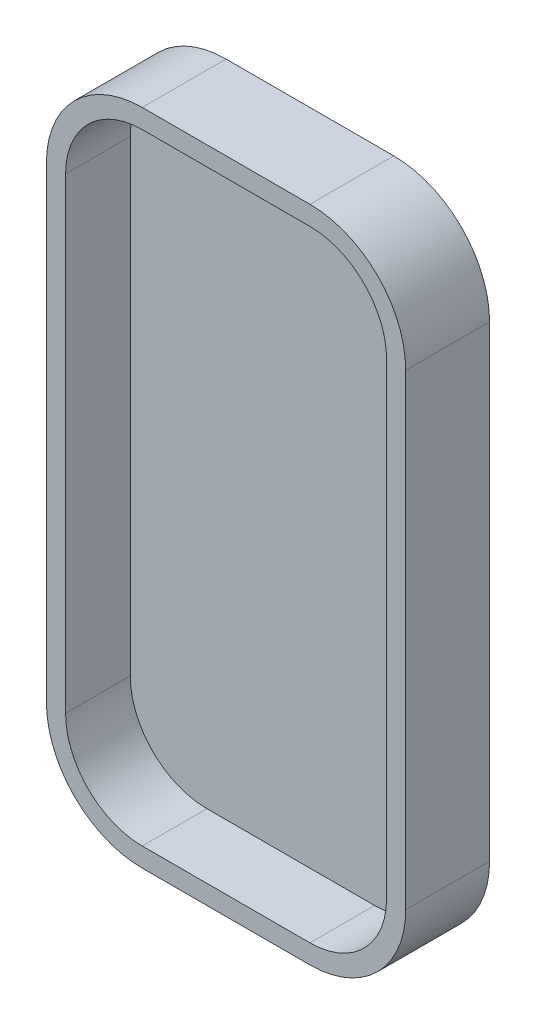
from build123d import *

# Parameters (mm, degrees)
BOSS_EXTRUDE1_DEPTH = 7
CUT_EXTRUDE1_DEPTH  = 5.4


with BuildPart() as part:
    # Sketch1 → Boss-Extrude1 (new body)
    with BuildSketch(Plane(origin=(0, 0, 0), x_dir=(0, 1, 0), z_dir=(0, 0, 1))):
        with BuildLine():
            Line((-19.5, 15), (19.5, 15))
            ThreePointArc((19.5, 15), (25.156854249, 12.656854249), (27.5, 7))
            Line((27.5, 7), (27.5, -7))
            ThreePointArc((27.5, -7), (25.156854249, -12.656854249), (19.5, -15))
            Line((19.5, -15), (-19.5, -15))
            ThreePointArc((-19.5, -15), (-25.156854249, -12.656854249), (-27.5, -7))
            Line((-27.5, -7), (-27.5, 7))
            ThreePointArc((-27.5, 7), (-25.156854249, 12.656854249), (-19.5, 15))
        make_face()
    extrude(amount=BOSS_EXTRUDE1_DEPTH)

    # Sketch2 → Cut-Extrude1 (cut)
    with BuildSketch(Plane.XY.offset(7)):
        with BuildLine():
            Line((7, -25.9), (-7, -25.9))
            ThreePointArc((-7, -25.9), (-11.5254834, -24.0254834), (-13.4, -19.5))
            Line((-13.4, -19.5), (-13.4, 19.5))
            ThreePointArc((-13.4, 19.5), (-11.5254834, 24.0254834), (-7, 25.9))
            Line((-7, 25.9), (7, 25.9))
            ThreePointArc((7, 25.9), (11.5254834, 24.0254834), (13.4, 19.5))
            Line((13.4, 19.5), (13.4, -19.5))
            ThreePointArc((13.4, -19.5), (11.5254834, -24.0254834), (7, -25.9))
        make_face()
    extrude(amount=-CUT_EXTRUDE1_DEPTH, mode=Mode.SUBTRACT)


solid = part.part
